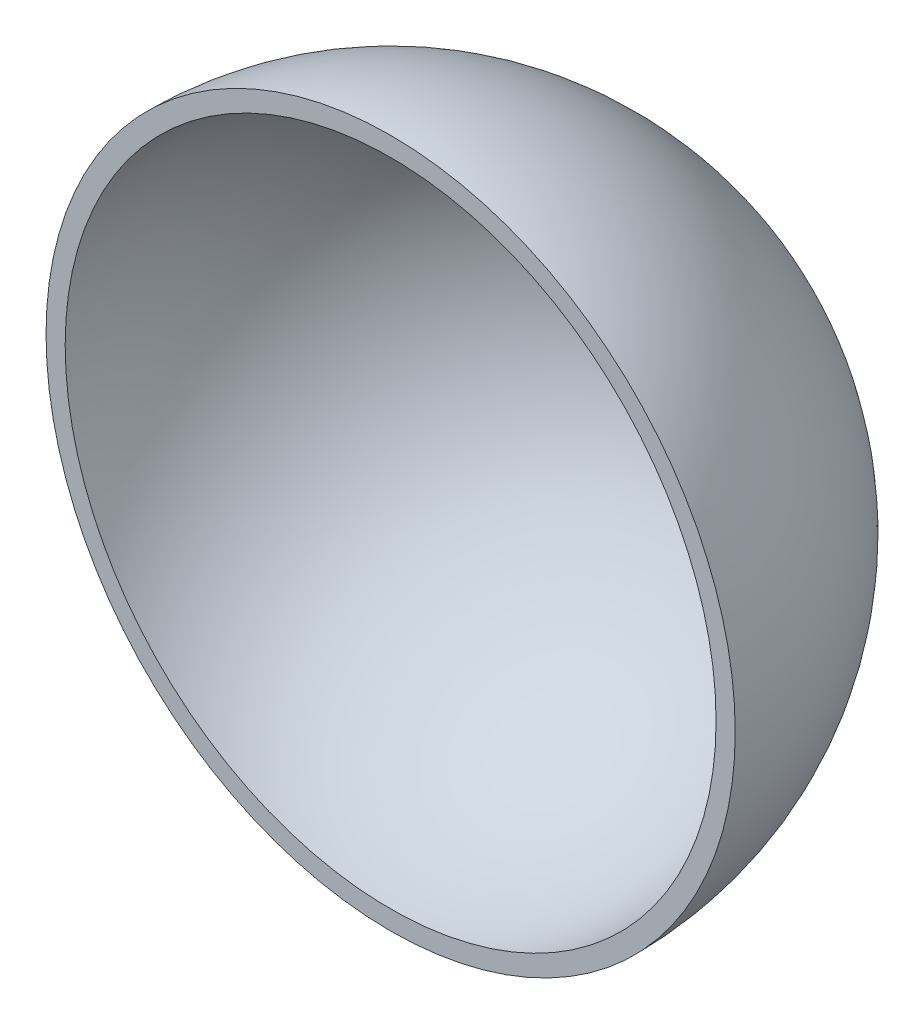
from build123d import *

# Parameters (mm, degrees)
REVOLVE1_ANGLE          = 180
CUT_EXTRUDE1_REACH      = 222.454
CUT_EXTRUDE1_END_RADIUS = 90
SKETCH1_3_R             = 2.5


with BuildPart() as part:
    # Sketch1 → Revolve1 (revolve)
    with BuildSketch(Plane.XY):
        with BuildLine():
            Line((0, 5), (0, 0))
            ThreePointArc((0, 0), (90, 90), (0, 180))
            Line((0, 180), (0, 175))
            ThreePointArc((0, 175), (85, 90), (0, 5))
        make_face()
    revolve(axis=Axis((0, 0, 0), (0, 1, 0)), revolution_arc=REVOLVE1_ANGLE)

    # Cut-Extrude1: up to this sphere (the profile starts inside it)
    cut_extrude1_end = Location((0, 90, 0)) * Sphere(CUT_EXTRUDE1_END_RADIUS, mode=Mode.PRIVATE)
    # Sketch1_3 → Cut-Extrude1 (cut, up to the surface)
    with BuildSketch(Plane.XY, mode=Mode.PRIVATE) as cut_extrude1_sk1:
        with Locations((0, 90)):
            Circle(SKETCH1_3_R)
    cut_extrude1_tool1 = extrude(cut_extrude1_sk1.sketch, amount=-CUT_EXTRUDE1_REACH, mode=Mode.PRIVATE) & cut_extrude1_end
    add(cut_extrude1_tool1.solids().sort_by_distance((0, 90, 0))[0], mode=Mode.SUBTRACT)


solid = part.part
